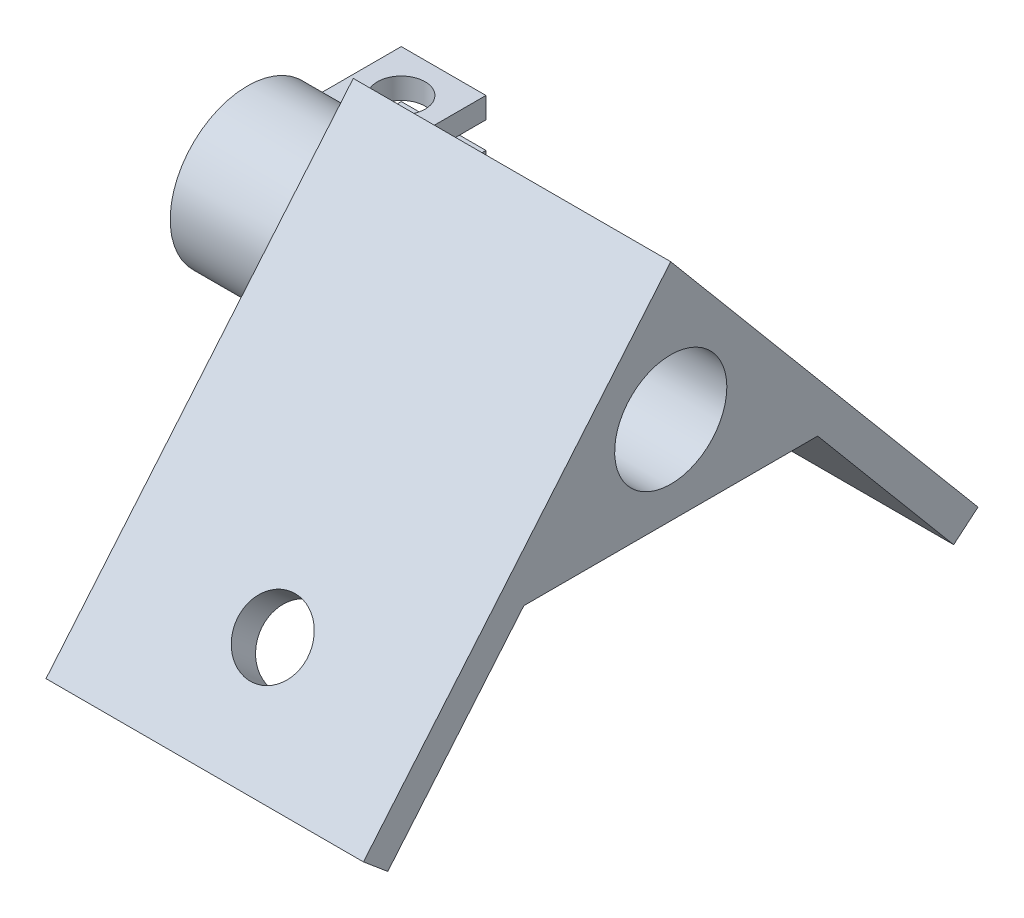
from build123d import *

# Parameters (mm, degrees)
SKETCH1_R            = 5.3
BOSS_EXTRUDE1_DEPTH  = 15
M6_CLEARANCE_HOLE1_D = 6.6
BOSS_EXTRUDE3_DEPTH  = 2
BOSS_EXTRUDE2_DEPTH  = 8
SKETCH6_R            = 2.25
CUT_EXTRUDE1_DEPTH   = 27.870888862


with BuildPart() as part:
    # Sketch1 → Boss-Extrude1 (new body, symmetric)
    with BuildSketch(Plane(origin=(0, 0, 0), x_dir=(0, 0, -1), z_dir=(1, 0, 0))):
        Polygon((0, 12.912507763), (-29.037071095, -21.692526033), (-26.738937766, -23.620888862), (-13.883185572, -8.3), (13.883185572, -8.3), (26.738937766, -23.620888862), (29.037071095, -21.692526033), align=None)
        Circle(SKETCH1_R, mode=Mode.SUBTRACT)
    extrude(amount=BOSS_EXTRUDE1_DEPTH, both=True)

    # M6 Clearance Hole1 (through all)
    with Locations(Plane(origin=(0, 3.406774331, 4.060035549), x_dir=(-1, 0, 0), z_dir=(0, -0.64278761, -0.766044443))):
        with Locations((0, -25.282108547)):
            m6_clearance_hole1 = Hole(M6_CLEARANCE_HOLE1_D / 2)

    # Mirror1: M6 Clearance Hole1 across plane
    add(m6_clearance_hole1.mirror(Plane.XY), mode=Mode.SUBTRACT)

    # Sketch7 → Boss-Extrude3 (add)
    with BuildSketch(Plane.ZY.offset(15)):
        with BuildLine():
            Line((-5.150485414, 1.25), (-7.192183257, 1.25))
            ThreePointArc((-7.192183257, 1.25), (7.3, 0), (-7.192183257, -1.25))
            Line((-7.192183257, -1.25), (-5.150485414, -1.25))
            ThreePointArc((-5.150485414, -1.25), (5.3, 0), (-5.150485414, 1.25))
        make_face()
    extrude(amount=BOSS_EXTRUDE3_DEPTH)

    # Sketch5 → Boss-Extrude2 (add)
    with BuildSketch(Plane.ZY.offset(17)):
        with BuildLine():
            Line((-5.150485414, 1.25), (-14.536627571, 1.25))
            Line((-14.536627571, 1.25), (-14.536627571, 3.25))
            Line((-14.536627571, 3.25), (-6.536627571, 3.25))
            ThreePointArc((-6.536627571, 3.25), (7.3, 0), (-6.536627571, -3.25))
            Line((-6.536627571, -3.25), (-6.536627571, -10.25))
            Line((-6.536627571, -10.25), (-14.536627571, -10.25))
            Line((-14.536627571, -10.25), (-14.536627571, -1.25))
            Line((-14.536627571, -1.25), (-5.150485414, -1.25))
            ThreePointArc((-5.150485414, -1.25), (5.3, 0), (-5.150485414, 1.25))
        make_face()
    extrude(amount=BOSS_EXTRUDE2_DEPTH)

    # Sketch6 → Cut-Extrude1 (cut, through all)
    with BuildSketch(Plane(origin=(0, 3.25, 0), x_dir=(1, 0, 0), z_dir=(0, 1, 0))):
        with Locations((-21, 10.536627571)):
            Circle(SKETCH6_R)
    extrude(amount=-CUT_EXTRUDE1_DEPTH, mode=Mode.SUBTRACT)


solid = part.part
